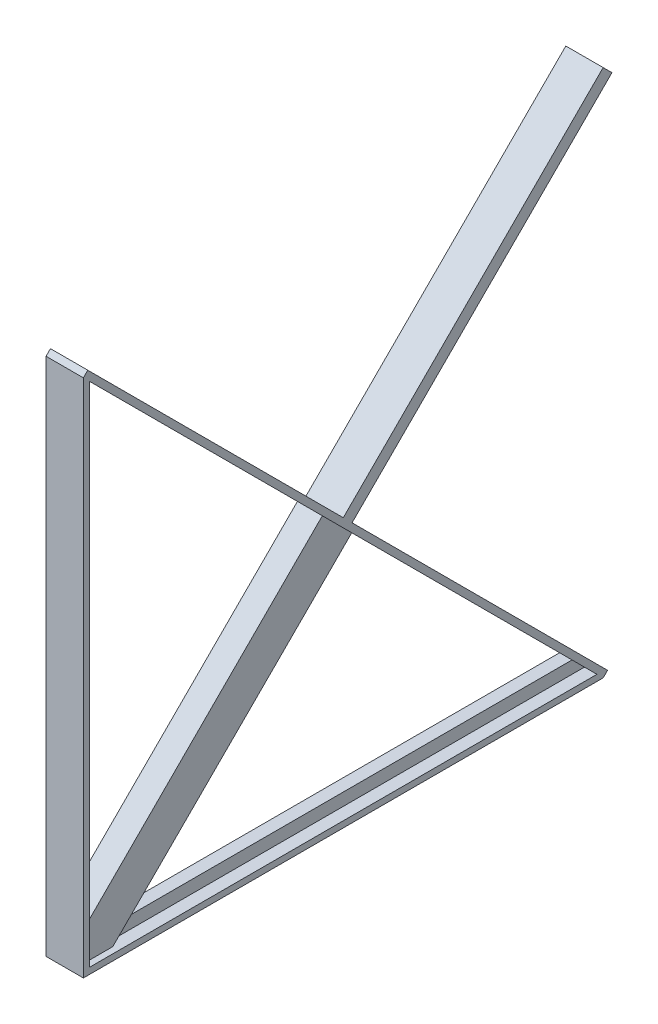
from build123d import *

# Parameters (mm, degrees)
EXTRUDE_2_DEPTH      = 76.2
EXTRUDE_2_DEPTH_BACK = 76.2
EXTRUDE_3_DEPTH      = 25.4
EXTRUDE_3_DEPTH_BACK = 25.4
SKETCH_4_W           = 152.4
SKETCH_4_H           = 2999.999514134
EXTRUDE_4_DEPTH      = 25.4
EXTRUDE_5_DEPTH      = 25.4
EXTRUDE_5_DEPTH_BACK = 76.2
SKETCH_6_W           = 152.4
SKETCH_6_H           = 50.8
EXTRUDE_6_DEPTH      = 1500


with BuildPart() as part:
    # 草图1 → 凸台-拉伸2 (new, two sides: drawn at the far end of the back side and taken through both)
    with BuildSketch(Plane(origin=(0, 0, 0), x_dir=(0, 0, -1), z_dir=(1, 0, 0)).offset(-EXTRUDE_2_DEPTH_BACK)):
        Polygon((0, 0), (0, 2121.32), (25.4, 2095.92), (25.4, 25.4), (2095.92, 25.4), (2121.32, 0), align=None)
    extrude(amount=EXTRUDE_2_DEPTH + EXTRUDE_2_DEPTH_BACK)

    # 草图3 → 凸台-拉伸3 (add, two sides: drawn at the far end of the back side and taken through both)
    with BuildSketch(Plane(origin=(0, 0, 0), x_dir=(0, 0, -1), z_dir=(1, 0, 0)).offset(-EXTRUDE_3_DEPTH_BACK)):
        Polygon((25.4, 2095.92), (25.4, 25.4), (2095.92, 25.4), (2045.12, 76.2), (76.2, 76.2), (76.2, 2045.12), align=None)
    extrude(amount=EXTRUDE_3_DEPTH + EXTRUDE_3_DEPTH_BACK)

    # 草图4 → 凸台-拉伸4 (add)
    with BuildSketch(Plane(origin=(0, 1060.66, -1060.66), x_dir=(1, 0, 0), z_dir=(0, 0.7071067811865493, -0.7071067811865457))):
        Rectangle(SKETCH_4_W, SKETCH_4_H)
    extrude(amount=EXTRUDE_4_DEPTH)

    # 草图5 → 凸台-拉伸5 (add, two sides: drawn at the far end of the back side and taken through both)
    with BuildSketch(Plane(origin=(25.4, 0, 0), x_dir=(0, 0, -1), z_dir=(1, 0, 0)).offset(-EXTRUDE_5_DEPTH_BACK)):
        Polygon((25.4, 25.4), (25.4, 145.4), (1000.66, 1120.66), (1120.66, 1000.66), (145.4, 25.4), align=None)
    extrude(amount=EXTRUDE_5_DEPTH + EXTRUDE_5_DEPTH_BACK)

    # 草图6 → 凸台-拉伸6 (add)
    with BuildSketch(Plane(origin=(0, 1078.620512242, -1078.620512242), x_dir=(1, 0, 0), z_dir=(0, 0.7071067811865495, -0.7071067811865457))):
        Rectangle(SKETCH_6_W, SKETCH_6_H)
    extrude(amount=EXTRUDE_6_DEPTH)


solid = part.part
